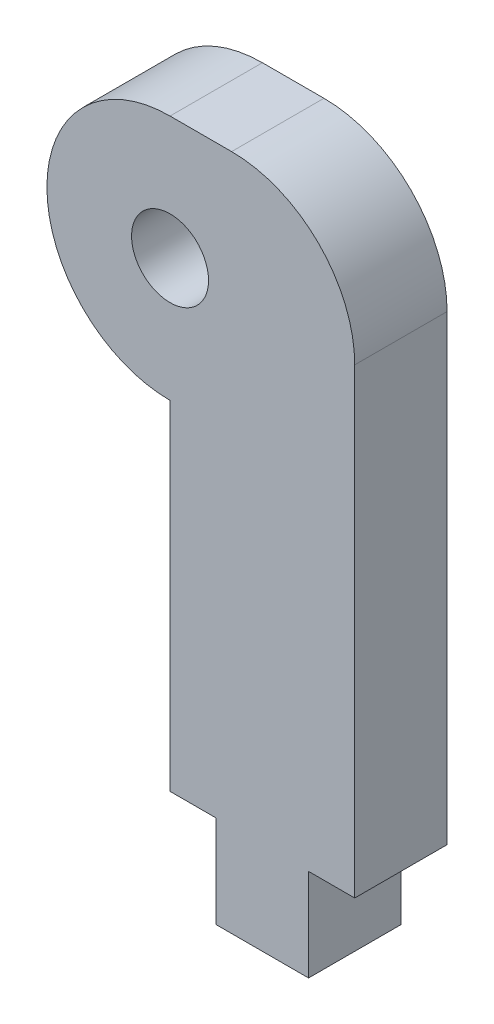
from build123d import *

# Parameters (mm, degrees)
SKETCH2_R           = 1.25
BOSS_EXTRUDE1_DEPTH = 3
FILLET1_R           = 4


with BuildPart() as part:
    # Sketch2 → Boss-Extrude1 (new body)
    with BuildSketch(Plane.XY):
        with BuildLine():
            Line((6, 4), (6, -15))
            Line((6, -15), (4.5, -15))
            Line((4.5, -15), (4.5, -18))
            Line((4.5, -18), (1.5, -18))
            Line((1.5, -18), (1.5, -15))
            Line((1.5, -15), (0, -15))
            Line((0, -15), (0, -4))
            ThreePointArc((0, -4), (-4, 0), (0, 4))
            Line((0, 4), (6, 4))
        make_face()
        Circle(SKETCH2_R, mode=Mode.SUBTRACT)
    extrude(amount=BOSS_EXTRUDE1_DEPTH)

    # Fillet1
    fillet1_edges = [part.edges().sort_by_distance(p)[0] for p in [
        (6, 4, 1.5),
    ]]
    fillet(fillet1_edges, radius=FILLET1_R)


solid = part.part
